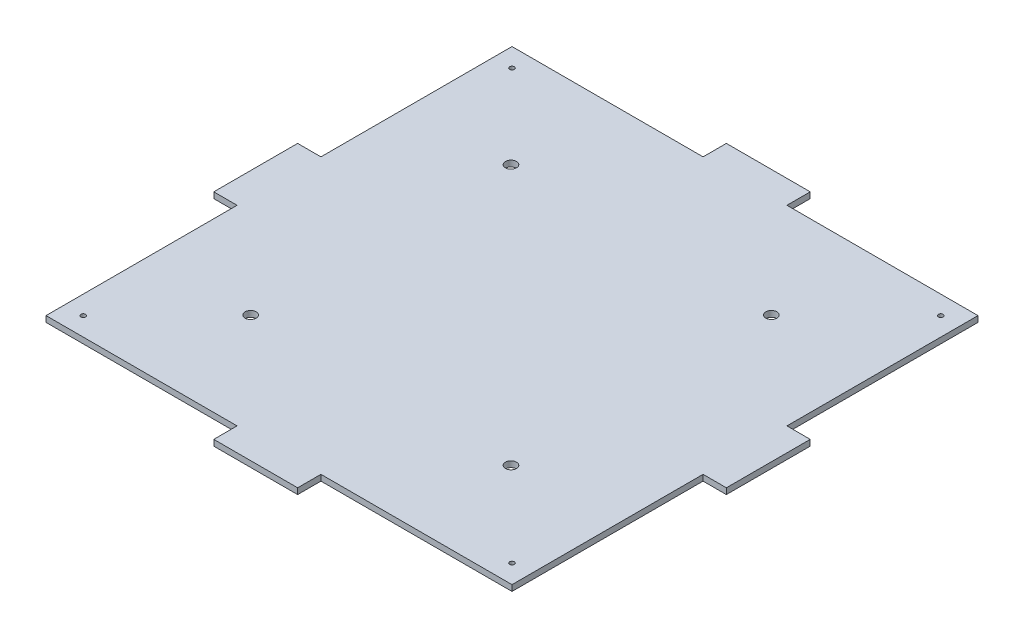
from build123d import *

# Parameters (mm, degrees)
SKETCH2_W           = 250
SKETCH2_H           = 250
BOSS_EXTRUDE1_DEPTH = 3.175
SKETCH10_W          = 45
SKETCH10_H          = 3.175
BOSS_EXTRUDE2_DEPTH = 12.5
SKETCH11_W          = 45
SKETCH11_H          = 3.175
BOSS_EXTRUDE3_DEPTH = 12.5
SKETCH13_W          = 45
SKETCH13_H          = 3.175
BOSS_EXTRUDE4_DEPTH = 12.5
SKETCH14_W          = 45
SKETCH14_H          = 3.175
BOSS_EXTRUDE5_DEPTH = 12.5
M3_TAPPED_HOLE1_D   = 2.5
SKETCH21_R          = 1.25
CUT_EXTRUDE2_DEPTH  = 10
SKETCH23_R          = 2.9718
CUT_EXTRUDE10_DEPTH = 10


with BuildPart() as part:
    # Sketch2 → Boss-Extrude1 (new body)
    with BuildSketch(Plane(origin=(0, 0, 0), x_dir=(1, 0, 0), z_dir=(0, 1, 0))):
        Rectangle(SKETCH2_W, SKETCH2_H)
    extrude(amount=BOSS_EXTRUDE1_DEPTH)

    # Sketch10 → Boss-Extrude2 (add)
    with BuildSketch(Plane(origin=(0, 0, -125), x_dir=(-1, 0, 0), z_dir=(0, 0, -1))):
        with Locations((0, 1.5875)):
            Rectangle(SKETCH10_W, SKETCH10_H)
    extrude(amount=BOSS_EXTRUDE2_DEPTH)

    # Sketch11 → Boss-Extrude3 (add)
    with BuildSketch(Plane.ZY.offset(125)):
        with Locations((0, 1.5875)):
            Rectangle(SKETCH11_W, SKETCH11_H)
    extrude(amount=BOSS_EXTRUDE3_DEPTH)

    # Sketch13 → Boss-Extrude4 (add)
    with BuildSketch(Plane.XY.offset(125)):
        with Locations((0, 1.5875)):
            Rectangle(SKETCH13_W, SKETCH13_H)
    extrude(amount=BOSS_EXTRUDE4_DEPTH)

    # Sketch14 → Boss-Extrude5 (add)
    with BuildSketch(Plane(origin=(125, 0, 0), x_dir=(0, 0, -1), z_dir=(1, 0, 0))):
        with Locations((0, 1.5875)):
            Rectangle(SKETCH14_W, SKETCH14_H)
    extrude(amount=BOSS_EXTRUDE5_DEPTH)

    # M3 Tapped Hole1 (through all)
    with Locations(Plane(origin=(-115, 3.175, -115), x_dir=(0, 0, 1), z_dir=(0, 1, 0))):
        with Locations((0, 0)):
            Hole(M3_TAPPED_HOLE1_D / 2)

    # Sketch21 → Cut-Extrude2 (cut)
    with BuildSketch(Plane(origin=(0, 3.175, 0), x_dir=(1, 0, 0), z_dir=(0, 1, 0))):
        with Locations((115, 115)):
            Circle(SKETCH21_R)
        with Locations((115, -115)):
            Circle(SKETCH21_R)
        with Locations((-115, -115)):
            Circle(SKETCH21_R)
    extrude(amount=-CUT_EXTRUDE2_DEPTH, mode=Mode.SUBTRACT)

    # Sketch23 → Cut-Extrude10 (cut)
    with BuildSketch(Plane(origin=(0, 3.175, 0), x_dir=(1, 0, 0), z_dir=(0, 1, 0))):
        with Locations((-70.403440877, -69.85)):
            Circle(SKETCH23_R)
        with Locations((-70.403440877, 69.85)):
            Circle(SKETCH23_R)
        with Locations((69.296559123, 69.85)):
            Circle(SKETCH23_R)
        with Locations((69.296559123, -69.85)):
            Circle(SKETCH23_R)
    extrude(amount=-CUT_EXTRUDE10_DEPTH, mode=Mode.SUBTRACT)


solid = part.part
